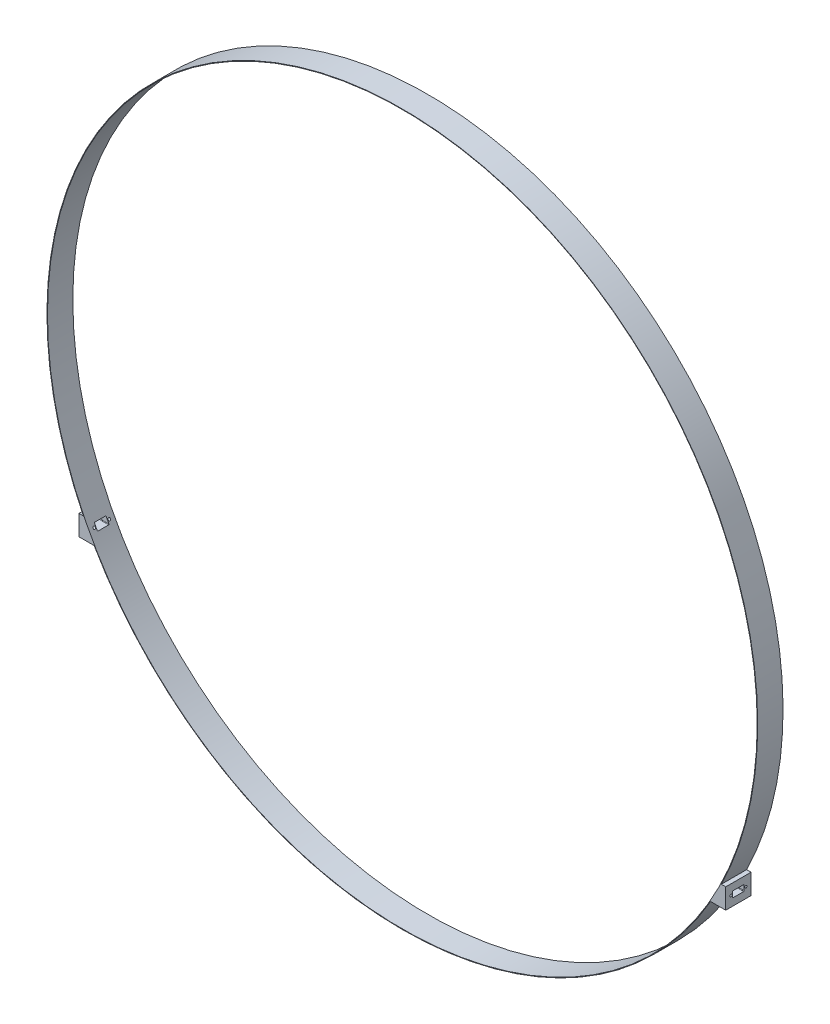
from build123d import *

# Parameters (mm, degrees)
SKETCH1_R      = 701
SKETCH1_R_2    = 700
EXTRUDE1_DEPTH = 50
EXTRUDE4_DEPTH = 50
SKETCH5_R      = 2.25
EXTRUDE5_DEPTH = 1500


with BuildPart() as part:
    # Sketch1 → Extrude1 (new body)
    with BuildSketch(Plane.XY):
        Circle(SKETCH1_R)
        Circle(SKETCH1_R_2, mode=Mode.SUBTRACT)
    extrude(amount=-EXTRUDE1_DEPTH)

    # Sketch4 → Extrude4 (add)
    with BuildSketch(Plane.XY):
        with BuildLine():
            Line((-629.221741519, -309), (-637.947366143, -309))
            Line((-637.947366143, -309), (-637.947366143, -349))
            Line((-637.947366143, -349), (-607.947366143, -349))
            ThreePointArc((-607.947366143, -349), (-618.907788154, -329.171915208), (-629.221741519, -309))
        make_face()
    extrude4 = extrude(amount=-EXTRUDE4_DEPTH)

    # Mirror1: Extrude4 across plane
    add(extrude4.mirror(Plane(origin=(0, 0, 0), x_dir=(0, 0, 1), z_dir=(1, 0, 0))))

    # Sketch5 → Extrude5 (cut)
    with BuildSketch(Plane(origin=(637.947366143, 0, 0), x_dir=(0, 0, -1), z_dir=(1, 0, 0))):
        with Locations((10.387864663, -328.839889929)):
            Circle(SKETCH5_R)
        with Locations((39.787864663, -328.839889929)):
            Circle(SKETCH5_R)
        with BuildLine():
            Line((14.5, -322.839889929), (35.5, -322.839889929))
            ThreePointArc((35.5, -322.839889929), (36.207106781, -323.132783148), (36.5, -323.839889929))
            Line((36.5, -323.839889929), (36.5, -333.839889929))
            ThreePointArc((36.5, -333.839889929), (36.207106781, -334.54699671), (35.5, -334.839889929))
            Line((35.5, -334.839889929), (14.5, -334.839889929))
            ThreePointArc((14.5, -334.839889929), (13.792893219, -334.54699671), (13.5, -333.839889929))
            Line((13.5, -333.839889929), (13.5, -323.839889929))
            ThreePointArc((13.5, -323.839889929), (13.792893219, -323.132783148), (14.5, -322.839889929))
        make_face()
    extrude(amount=-EXTRUDE5_DEPTH, mode=Mode.SUBTRACT)


solid = part.part
